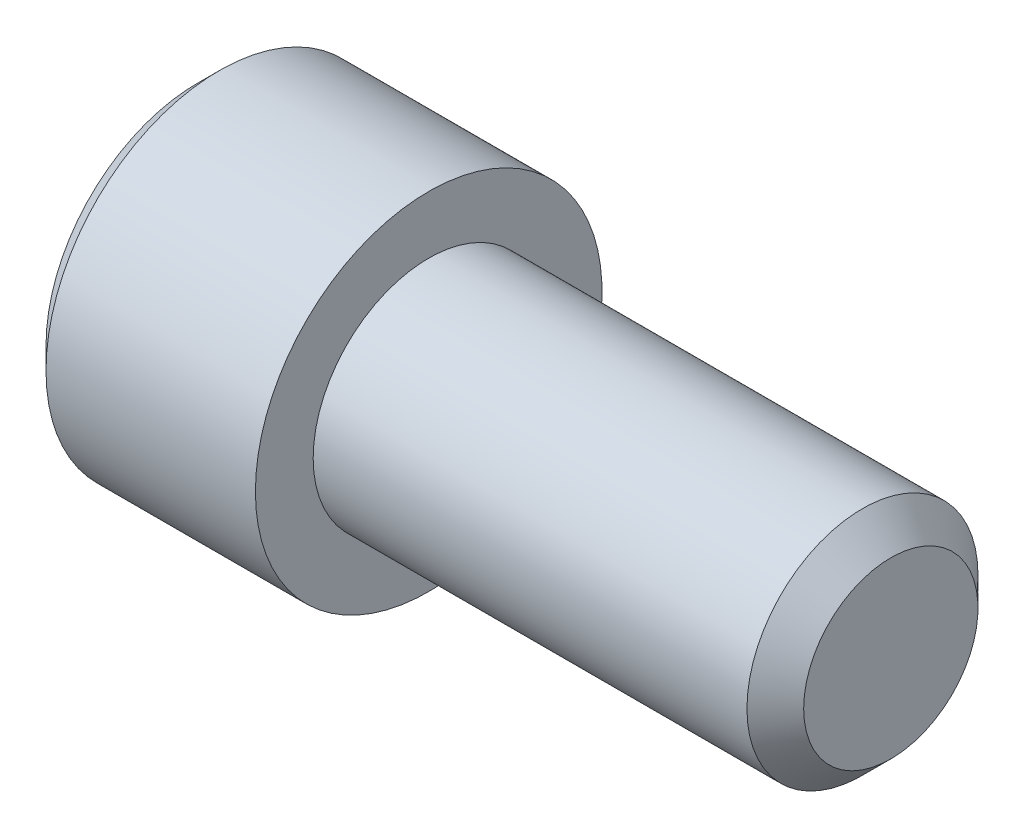
from build123d import *

# Parameters (mm, degrees)
CUT_EXTRUDE1_DEPTH = 1


with BuildPart() as part:
    # Sketch1 → Revolve1 (revolve)
    with BuildSketch(Plane.XY):
        Polygon((-2, 0), (-2, 1.3125), (-1.8125, 1.5), (0, 1.5), (0, 1), (3.7545, 1), (4, 0.7545), (4, 0), align=None)
    revolve(axis=Axis((4, 0, 0), (-1, 0, 0)))

    # Sketch2 → Cut-Revolve1 (revolve, cut)
    with BuildSketch(Plane.XY):
        Polygon((-2, 0), (-2, 0.9), (-1.85, 0.75), (-1, 0.75), (-0.6, 0), align=None)
    revolve(axis=Axis((-0.6, 0, 0), (-1, 0, 0)), mode=Mode.SUBTRACT)

    # Sketch3 → Cut-Extrude1 (cut)
    with BuildSketch(Plane(origin=(-2, 0, 0), x_dir=(0, 0, -1), z_dir=(1, 0, 0))):
        Polygon((-0.75, -0.433012702), (0, -0.866025404), (0.75, -0.433012702), (0.75, 0.433012702), (0, 0.866025404), (-0.75, 0.433012702), align=None)
    extrude(amount=CUT_EXTRUDE1_DEPTH, mode=Mode.SUBTRACT)


solid = part.part
